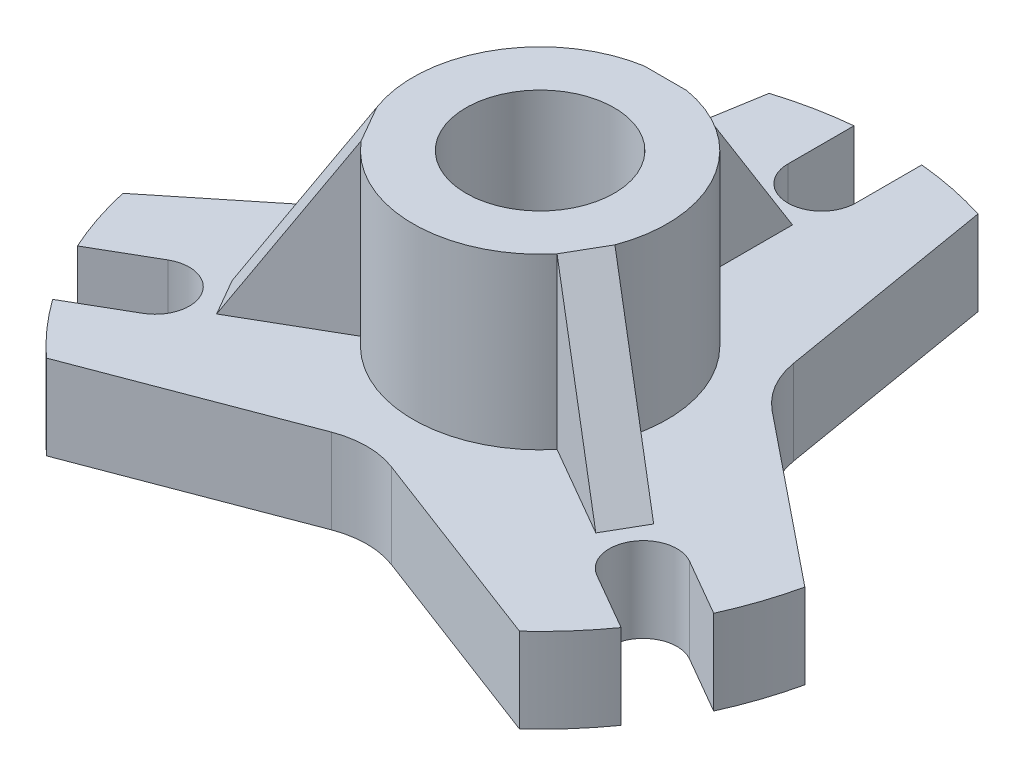
from build123d import *

# Parameters (mm, degrees)
SKETCH1_R           = 82.5
SKETCH1_R_2         = 30
BOSS_EXTRUDE2_DEPTH = 20
SKETCH1_4_R         = 30
SKETCH1_4_R_2       = 17.5
BOSS_EXTRUDE3_DEPTH = 60
SKETCH3_W           = 50
SKETCH3_H           = 40
BOSS_EXTRUDE4_DEPTH = 5
CIRPATTERN1_COUNT   = 3
CUT_EXTRUDE5_DEPTH  = 10
CIRPATTERN4_COUNT   = 3
CUT_EXTRUDE7_DEPTH  = 124.338963835
CIRPATTERN5_COUNT   = 3
CUT_EXTRUDE8_DEPTH  = 124.338963835
FILLET1_R           = 20


with BuildPart() as part:
    # Sketch1 → Boss-Extrude2 (new body)
    with BuildSketch(Plane(origin=(0, 0, 0), x_dir=(1, 0, 0), z_dir=(0, 1, 0))):
        Circle(SKETCH1_R)
        Circle(SKETCH1_R_2, mode=Mode.SUBTRACT)
    extrude(amount=BOSS_EXTRUDE2_DEPTH)

    # Sketch1_4 → Boss-Extrude3 (add)
    with BuildSketch(Plane(origin=(0, 0, 0), x_dir=(1, 0, 0), z_dir=(0, 1, 0))):
        Circle(SKETCH1_4_R)
        Circle(SKETCH1_4_R_2, mode=Mode.SUBTRACT)
    extrude(amount=BOSS_EXTRUDE3_DEPTH)

    # Sketch3 → Boss-Extrude4 (add, symmetric)
    with BuildSketch(Plane(origin=(0, 0, 0), x_dir=(0, 0, -1), z_dir=(1, 0, 0))):
        with Locations((42.5, 40)):
            Rectangle(SKETCH3_W, SKETCH3_H)
    boss_extrude4 = extrude(amount=BOSS_EXTRUDE4_DEPTH, both=True)

    # CirPattern1: Boss-Extrude4 ×3 about axis
    cirpattern1_axis = Axis((0, 60, 0), (0, 1, 0))
    for i in range(1, CIRPATTERN1_COUNT):
        add(boss_extrude4.rotate(cirpattern1_axis, i * 360 / CIRPATTERN1_COUNT))

    # Sketch15 → Cut-Extrude5 (cut)
    with BuildSketch(Plane(origin=(5, 0, 0), x_dir=(0, 0, -1), z_dir=(1, 0, 0))):
        Polygon((29.580398915, 60), (54.580398915, 20), (67.5, 20), (67.5, 60), align=None)
    cut_extrude5 = extrude(amount=-CUT_EXTRUDE5_DEPTH, mode=Mode.SUBTRACT)

    # CirPattern4: Cut-Extrude5 ×3 about axis
    cirpattern4_axis = Axis((0, 60, 0), (0, 1, 0))
    for i in range(1, CIRPATTERN4_COUNT):
        add(cut_extrude5.rotate(cirpattern4_axis, i * 360 / CIRPATTERN4_COUNT), mode=Mode.SUBTRACT)

    # Sketch22 → Cut-Extrude7 (cut, through all)
    with BuildSketch(Plane(origin=(0, 20, 0), x_dir=(1, 0, 0), z_dir=(0, 1, 0))):
        with BuildLine():
            Line((8, 66.5), (8, 82.111205082))
            ThreePointArc((8, 82.111205082), (0, 82.5), (-8, 82.111205082))
            Line((-8, 82.111205082), (-8, 66.5))
            ThreePointArc((-8, 66.5), (0, 58.5), (8, 66.5))
        make_face()
    cut_extrude7 = extrude(amount=-CUT_EXTRUDE7_DEPTH, mode=Mode.SUBTRACT)

    # CirPattern5: Cut-Extrude7 ×3 about axis
    cirpattern5_axis = Axis((0, 60, 0), (0, 1, 0))
    for i in range(1, CIRPATTERN5_COUNT):
        add(cut_extrude7.rotate(cirpattern5_axis, i * 360 / CIRPATTERN5_COUNT), mode=Mode.SUBTRACT)

    # Sketch29 → Cut-Extrude8 (cut, through all)
    with BuildSketch(Plane(origin=(0, 20, 0), x_dir=(1, 0, 0), z_dir=(0, 1, 0))):
        with BuildLine():
            Line((-80.510468766, -18.008731746), (-34.681233917, 18.959795028))
            Line((-34.681233917, 18.959795028), (-24.659817795, 78.728288349))
            ThreePointArc((-24.659817795, 78.728288349), (-71.447253677, 41.249726568), (-80.510468766, -18.008731746))
        make_face()
        with BuildLine():
            Line((24.659817795, 78.728288349), (34.681233917, 18.959795028))
            Line((34.681233917, 18.959795028), (80.510468766, -18.008731746))
            ThreePointArc((80.510468766, -18.008731746), (71.447253677, 41.249726568), (24.659817795, 78.728288349))
        make_face()
        with BuildLine():
            Line((-55.850650713, -60.720299859), (0, -39.52545779))
            Line((0, -39.52545779), (55.850650713, -60.720299859))
            ThreePointArc((55.850650713, -60.720299859), (0, -82.5), (-55.850650713, -60.720299859))
        make_face()
    extrude(amount=-CUT_EXTRUDE8_DEPTH, mode=Mode.SUBTRACT)

    # Fillet1
    fillet1_edges = [part.edges().sort_by_distance(p)[0] for p in [
        (-34.681233917, 10, -18.959795028),
        (0, 10, 39.52545779),
        (34.681233917, 10, -18.959795028),
    ]]
    fillet(fillet1_edges, radius=FILLET1_R)


solid = part.part
